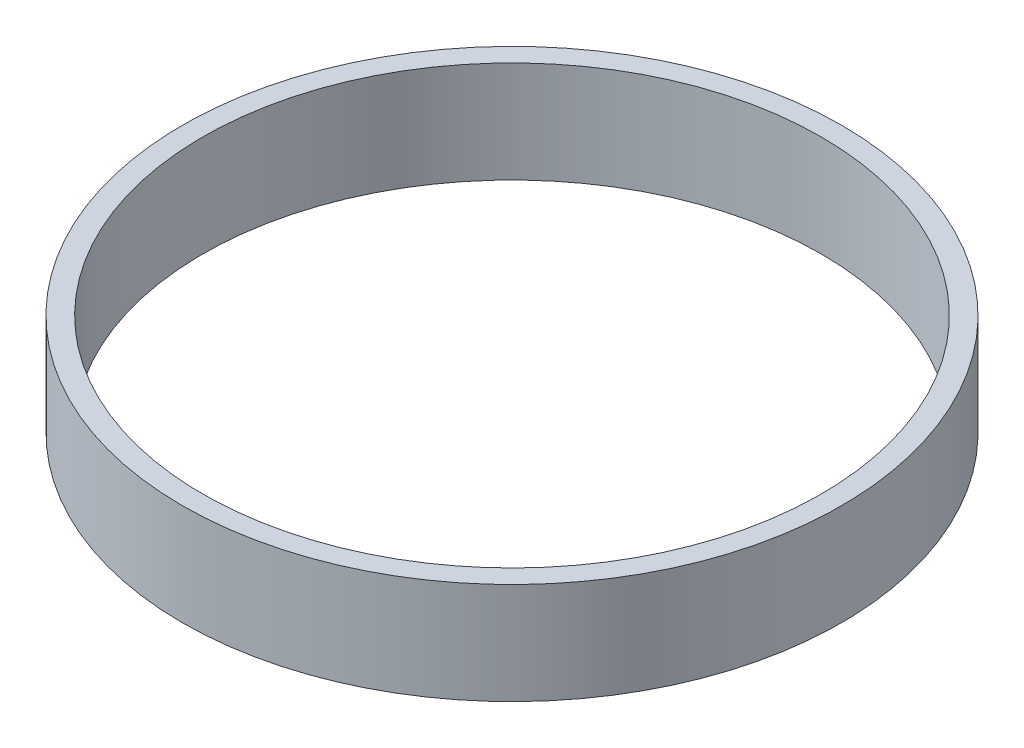
from build123d import *

# Parameters (mm, degrees)
ESBO_O1_W = 2
ESBO_O1_H = 10


with BuildPart() as part:
    # Esboço1 → Revolução1 (revolve)
    with BuildSketch(Plane.XY):
        with Locations((31.5, 5)):
            Rectangle(ESBO_O1_W, ESBO_O1_H)
    revolve(axis=Axis((0, -0.5, 0), (0, 1, 0)))


solid = part.part
